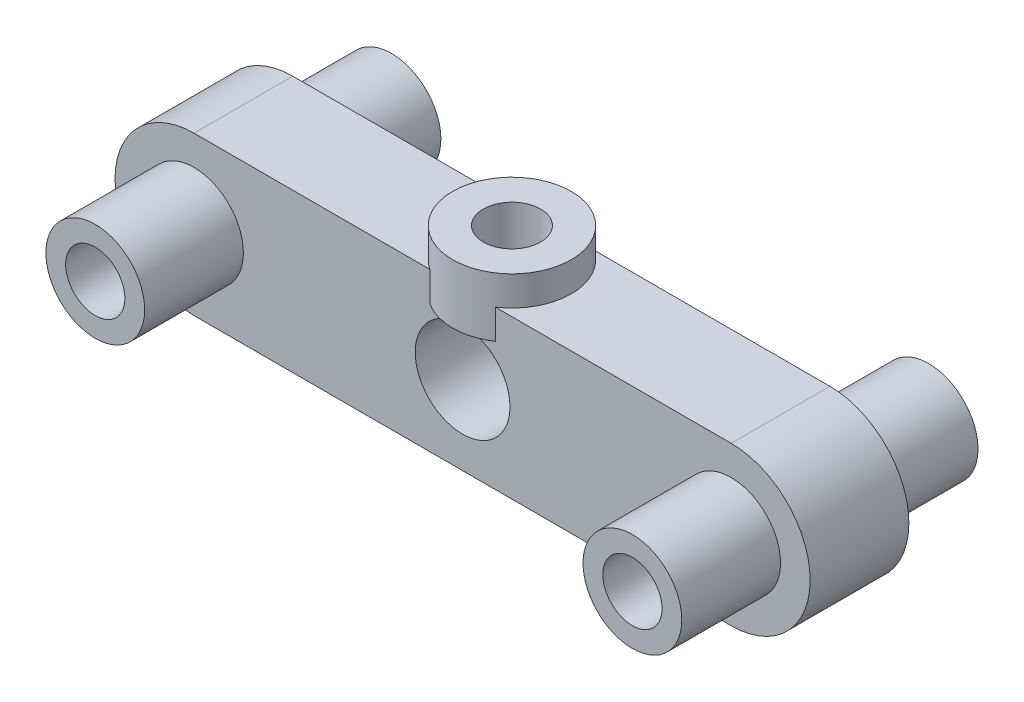
from build123d import *

# Parameters (mm, degrees)
SKETCH1_R           = 2.4
BOSS_EXTRUDE1_DEPTH = 5
SKETCH5_R           = 3
BOSS_EXTRUDE3_DEPTH = 1.5
SKETCH6_R           = 1.45
CUT_EXTRUDE4_DEPTH  = 9
SKETCH2_R           = 1.45
CUT_EXTRUDE3_DEPTH  = 4
SKETCH7_R           = 2.5
SKETCH7_R_2         = 1.5
BOSS_EXTRUDE4_DEPTH = 5


with BuildPart() as part:
    # Sketch1 → Boss-Extrude1 (new body)
    with BuildSketch(Plane.XY):
        with BuildLine():
            Line((0, 4), (27.2, 4))
            ThreePointArc((27.2, 4), (31.2, 0), (27.2, -4))
            Line((27.2, -4), (0, -4))
            ThreePointArc((0, -4), (-4, 0), (0, 4))
        make_face()
        with Locations((13.6, 0)):
            Circle(SKETCH1_R, mode=Mode.SUBTRACT)
    extrude(amount=BOSS_EXTRUDE1_DEPTH)

    # Sketch5 → Boss-Extrude3 (add, symmetric)
    with BuildSketch(Plane(origin=(0, 4, 0), x_dir=(1, 0, 0), z_dir=(0, 1, 0))):
        with Locations((13.6, -2.5)):
            Circle(SKETCH5_R)
    extrude(amount=BOSS_EXTRUDE3_DEPTH, both=True)

    # Sketch6 → Cut-Extrude4 (cut)
    with BuildSketch(Plane.XY.offset(5)):
        with Locations((27.2, 0)):
            Circle(SKETCH6_R)
        Circle(SKETCH6_R)
    cut_extrude4 = extrude(amount=-CUT_EXTRUDE4_DEPTH, mode=Mode.SUBTRACT)

    # Sketch2 → Cut-Extrude3 (cut, symmetric)
    with BuildSketch(Plane(origin=(0, 4, 0), x_dir=(1, 0, 0), z_dir=(0, 1, 0))):
        with Locations((13.6, -2.5)):
            Circle(SKETCH2_R)
    extrude(amount=CUT_EXTRUDE3_DEPTH, both=True, mode=Mode.SUBTRACT)

    # Sketch7 → Boss-Extrude4 (add)
    with BuildSketch(Plane.XY.offset(5)):
        with Locations((27.2, 0)):
            Circle(SKETCH7_R)
        with Locations((27.2, 0)):
            Circle(SKETCH7_R_2, mode=Mode.SUBTRACT)
        Circle(SKETCH7_R)
        Circle(SKETCH7_R_2, mode=Mode.SUBTRACT)
    boss_extrude4 = extrude(amount=BOSS_EXTRUDE4_DEPTH)

    # Mirror1: Cut-Extrude4, Boss-Extrude4 across plane
    add(cut_extrude4.mirror(Plane(origin=(0, 0, 2.5), x_dir=(1, 0, 0), z_dir=(0, 0, -1))), mode=Mode.SUBTRACT)
    add(boss_extrude4.mirror(Plane(origin=(0, 0, 2.5), x_dir=(1, 0, 0), z_dir=(0, 0, -1))))


solid = part.part
